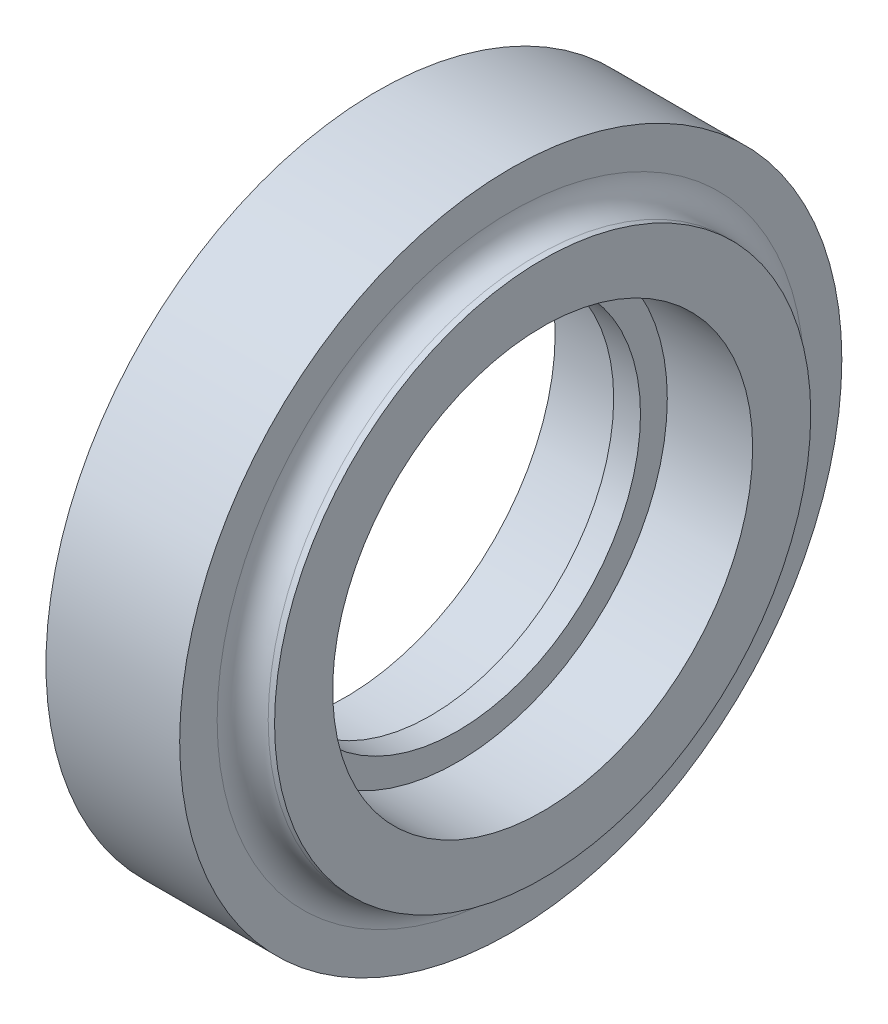
from build123d import *

# Parameters (mm, degrees)
EXTRUDECUTONE_DEPTH     = 10.800356134
PATTERNONE_COUNT        = 11
CUT_EXTRUDEA_DEPTH      = 72.376396027
CUT_EXTRUDEA_DEPTH_BACK = 72.376396027
SKETCHHOLE_R            = 23.5
SKETCH_3_OUTSIDE_W      = 129.786
SKETCH_3_OUTSIDE_H      = 128.809
SKETCH_3_OUTSIDE_R      = 37.048512268
CUT_EXTRUDE_4_DEPTH     = 74.898044777
SKETCH_4_R              = 23.5
SKETCH_4_R_2            = 20.5
EXTRUDE_1_DEPTH         = 1.5


with BuildPart() as part:
    # Sketch1 → Revolve 2 (revolve)
    with BuildSketch(Plane.XY):
        with BuildLine():
            Line((-11.050356134, 0), (-11.050356134, 30))
            Line((-11.050356134, 30), (-10.336534907, 30))
            ThreePointArc((-10.336534907, 30), (-8.317543587, 30.836293587), (-7.48125, 32.855284907))
            Line((-7.48125, 32.855284907), (-7.48125, 37.138212268))
            ThreePointArc((-7.48125, 37.138212268), (-6.685622836, 43.788705552), (-4.17925, 50))
            Line((-4.17925, 50), (4.17925, 50))
            ThreePointArc((4.17925, 50), (6.685622836, 43.788705552), (7.48125, 37.138212268))
            Line((7.48125, 37.138212268), (7.48125, 32.855284907))
            ThreePointArc((7.48125, 32.855284907), (8.317543587, 30.836293587), (10.336534907, 30))
            Line((10.336534907, 30), (11.050356134, 30))
            Line((11.050356134, 30), (11.050356134, 0))
            Line((11.050356134, 0), (-11.050356134, 0))
        make_face()
    revolve(axis=Axis((-4, 0, 0), (1, 0, 0)))

    # Sketch2 → ExtrudeCutOne (cut, symmetric)
    with BuildSketch(Plane(origin=(0, 0, 0), x_dir=(0, 0, -1), z_dir=(1, 0, 0))):
        with BuildLine():
            Line((8.716675765, 43.732789559), (9.255531143, 44.765919154))
            ThreePointArc((9.255531143, 44.765919154), (10.574511832, 46.771349182), (12.269067769, 48.471331487))
            ThreePointArc((12.269067769, 48.471331487), (0, 50), (-12.269067769, 48.471331487))
            ThreePointArc((-12.269067769, 48.471331487), (-10.574511832, 46.771349182), (-9.255531143, 44.765919154))
            Line((-9.255531143, 44.765919154), (-8.716675765, 43.732789559))
            ThreePointArc((-8.716675765, 43.732789559), (-7.522276521, 41.726996037), (-6.109966983, 39.868184863))
            ThreePointArc((-6.109966983, 39.868184863), (0, 37.048512268), (6.109966983, 39.868184863))
            ThreePointArc((6.109966983, 39.868184863), (7.522276521, 41.726996037), (8.716675765, 43.732789559))
        make_face()
    extrudecutone = extrude(amount=EXTRUDECUTONE_DEPTH, both=True, mode=Mode.SUBTRACT)

    # PatternOne: ExtrudeCutOne ×11 about axis
    patternone_axis = Axis((-4, 0, 0), (1, 0, 0))
    for i in range(1, PATTERNONE_COUNT):
        add(extrudecutone.rotate(patternone_axis, i * 360 / PATTERNONE_COUNT), mode=Mode.SUBTRACT)

    # SketchHole → Cut-ExtrudeA (cut, two sides: drawn at the far end of the back side and taken through both)
    with BuildSketch(Plane(origin=(0, 0, 0), x_dir=(0, 0, -1), z_dir=(1, 0, 0)).offset(-CUT_EXTRUDEA_DEPTH_BACK)):
        Circle(SKETCHHOLE_R)
    extrude(amount=CUT_EXTRUDEA_DEPTH + CUT_EXTRUDEA_DEPTH_BACK, mode=Mode.SUBTRACT)

    # 草图3 outside → 切除-拉伸4 (cut, through all)
    with BuildSketch(Plane(origin=(11.050356134, 0, 0), x_dir=(0, 0, -1), z_dir=(1, 0, 0))):
        with Locations((0, -0.7645)):
            Rectangle(SKETCH_3_OUTSIDE_W, SKETCH_3_OUTSIDE_H)
        Circle(SKETCH_3_OUTSIDE_R, mode=Mode.SUBTRACT)
    extrude(amount=-CUT_EXTRUDE_4_DEPTH, mode=Mode.SUBTRACT)

    # 草图4 → 凸台-拉伸1 (add, symmetric)
    with BuildSketch(Plane(origin=(0, 0, 0), x_dir=(0, 0, -1), z_dir=(1, 0, 0))):
        Circle(SKETCH_4_R)
        Circle(SKETCH_4_R_2, mode=Mode.SUBTRACT)
    extrude(amount=EXTRUDE_1_DEPTH, both=True)


solid = part.part
